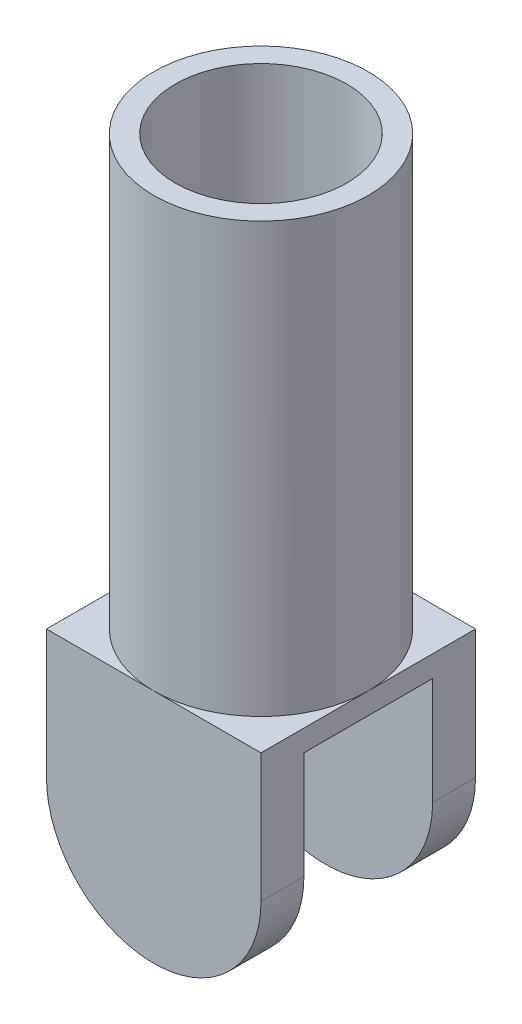
from build123d import *

# Parameters (mm, degrees)
SKETCH_1_W          = 10
SKETCH_1_H          = 10
EXTRUDE_1_DEPTH     = 11
SKETCH_2_R          = 5
SKETCH_2_R_2        = 4
EXTRUDE_2_DEPTH     = 20
SKETCH_3_W          = 6
SKETCH_3_H          = 10
CUT_EXTRUDE_1_DEPTH = 60
CUT_EXTRUDE_2_DEPTH = 60


with BuildPart() as part:
    # 草图1 → 凸台-拉伸1 (new body)
    with BuildSketch(Plane(origin=(0, 0, 0), x_dir=(1, 0, 0), z_dir=(0, 1, 0))):
        Rectangle(SKETCH_1_W, SKETCH_1_H)
    extrude(amount=EXTRUDE_1_DEPTH)

    # 草图2 → 凸台-拉伸2 (add)
    with BuildSketch(Plane(origin=(0, 11, 0), x_dir=(1, 0, 0), z_dir=(0, 1, 0))):
        Circle(SKETCH_2_R)
        Circle(SKETCH_2_R_2, mode=Mode.SUBTRACT)
    extrude(amount=EXTRUDE_2_DEPTH)

    # 草图3 → 切除-拉伸1 (cut)
    with BuildSketch(Plane(origin=(5, 0, 0), x_dir=(0, 0, -1), z_dir=(1, 0, 0))):
        with Locations((0, 5)):
            Rectangle(SKETCH_3_W, SKETCH_3_H)
    extrude(amount=-CUT_EXTRUDE_1_DEPTH, mode=Mode.SUBTRACT)

    # 草图4 → 切除-拉伸2 (cut)
    with BuildSketch(Plane.XY.offset(5)):
        with BuildLine():
            Line((-5, 5), (-5, -1.760834605))
            Line((-5, -1.760834605), (5, -1.760834605))
            Line((5, -1.760834605), (5, 5))
            ThreePointArc((5, 5), (0, 0), (-5, 5))
        make_face()
    extrude(amount=-CUT_EXTRUDE_2_DEPTH, mode=Mode.SUBTRACT)


solid = part.part
